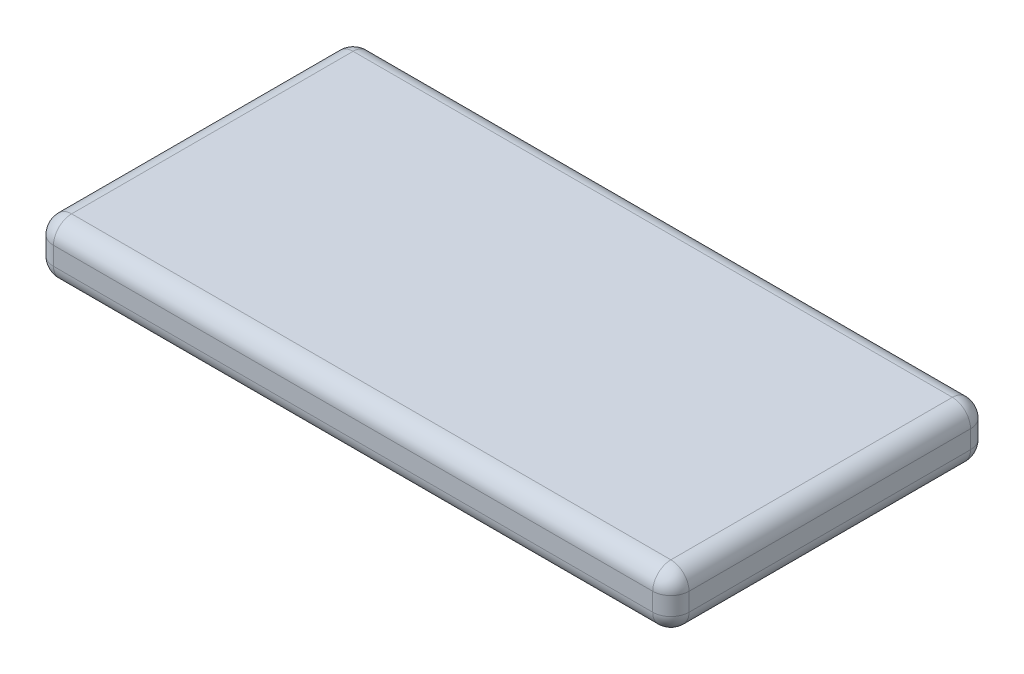
from build123d import *

# Parameters (mm, degrees)
SKETCH1_W           = 70
SKETCH1_H           = 35
BOSS_EXTRUDE1_DEPTH = 6
FILLET1_R           = 2


with BuildPart() as part:
    # Sketch1 → Boss-Extrude1 (new body)
    with BuildSketch(Plane(origin=(0, 0, 0), x_dir=(1, 0, 0), z_dir=(0, 1, 0))):
        with Locations((35, 17.5)):
            Rectangle(SKETCH1_W, SKETCH1_H)
    extrude(amount=BOSS_EXTRUDE1_DEPTH)

    # Fillet1
    fillet1_edges = [part.edges().sort_by_distance(p)[0] for p in [
        (0, 6, -17.5),
        (35, 6, 0),
        (70, 6, -17.5),
        (35, 0, 0),
        (0, 0, -17.5),
        (35, 0, -35),
        (70, 0, -17.5),
        (35, 6, -35),
        (70, 3, 0),
        (0, 3, 0),
        (0, 3, -35),
        (70, 3, -35),
    ]]
    fillet(fillet1_edges, radius=FILLET1_R)


solid = part.part
